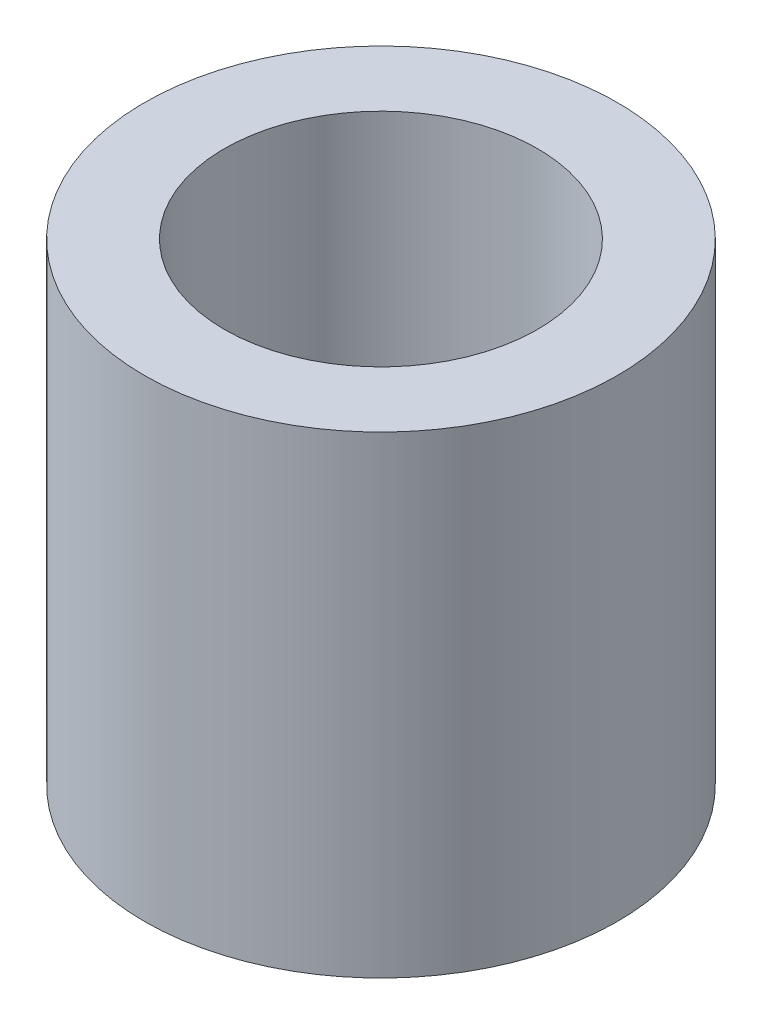
from build123d import *

# Parameters (mm, degrees)
SKETCH1_R           = 10
SKETCH1_R_2         = 4.5
BOSS_EXTRUDE1_DEPTH = 20
SKETCH2_R           = 6.625
CUT_EXTRUDE1_DEPTH  = 13
SKETCH3_R           = 6.625
CUT_EXTRUDE2_DEPTH  = 5


with BuildPart() as part:
    # Sketch1 → Boss-Extrude1 (new body)
    with BuildSketch(Plane(origin=(0, 0, 0), x_dir=(1, 0, 0), z_dir=(0, 1, 0))):
        Circle(SKETCH1_R)
        Circle(SKETCH1_R_2, mode=Mode.SUBTRACT)
    extrude(amount=BOSS_EXTRUDE1_DEPTH)

    # Sketch2 → Cut-Extrude1 (cut)
    with BuildSketch(Plane(origin=(0, 20, 0), x_dir=(1, 0, 0), z_dir=(0, 1, 0))):
        Circle(SKETCH2_R)
    extrude(amount=-CUT_EXTRUDE1_DEPTH, mode=Mode.SUBTRACT)

    # Sketch3 → Cut-Extrude2 (cut)
    with BuildSketch(Plane.XZ):
        Circle(SKETCH3_R)
    extrude(amount=-CUT_EXTRUDE2_DEPTH, mode=Mode.SUBTRACT)


solid = part.part
